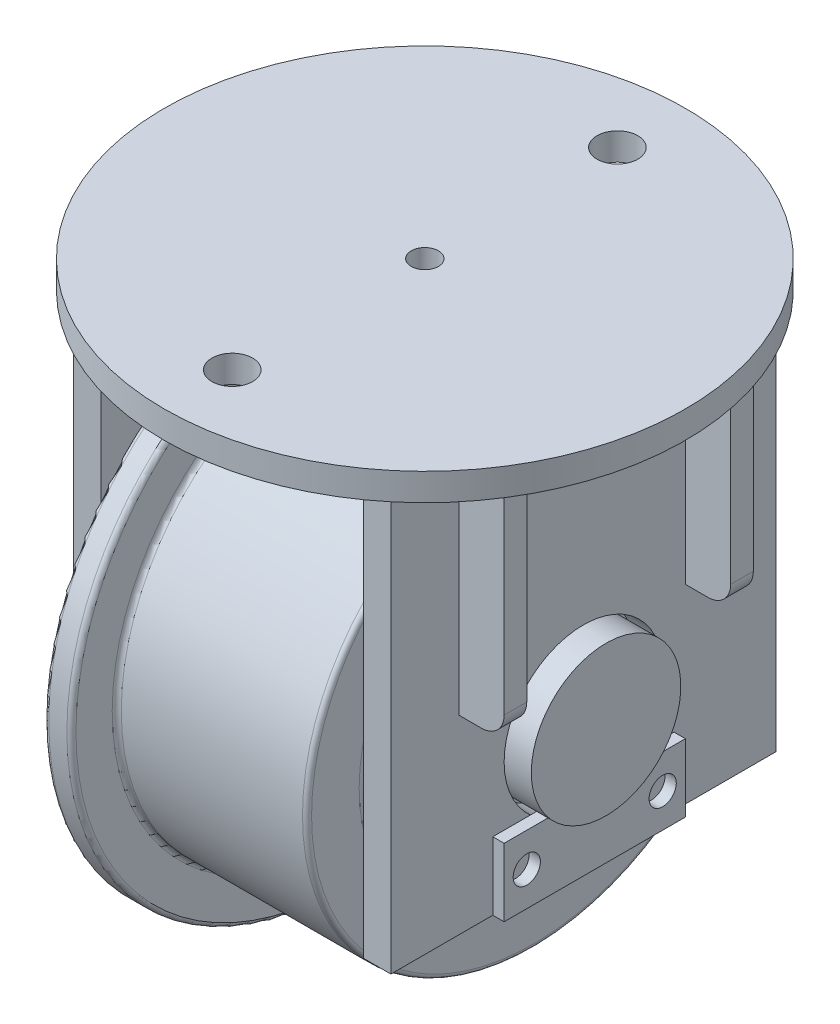
from build123d import *

# Parameters (mm, degrees)
SKETCH1_R            = 115
SKETCH1_R_2          = 9
SKETCH1_R_3          = 6
BOSS_EXTRUDE1_DEPTH  = 6
SKETCH2_W            = 12
SKETCH2_H            = 170
BOSS_EXTRUDE2_DEPTH  = 184
SKETCH3_R            = 35
CUT_EXTRUDE1_DEPTH   = 184
SKETCH6_W            = 10
SKETCH6_H            = 100
EXTRUDE_THIN1_DEPTH  = 20
FILLET2_R            = 10
FILLET2_OF_MIRROR1_R = 10
SKETCH5_W            = 158
SKETCH5_H            = 33
FILLET1_R            = 2
SKETCH7_W            = 80
SKETCH7_H            = 30
SKETCH7_R            = 6
BOSS_EXTRUDE3_DEPTH  = 5


with BuildPart() as part:
    # Sketch1 → Boss-Extrude1 (new body, symmetric)
    with BuildSketch(Plane(origin=(0, 0, 0), x_dir=(1, 0, 0), z_dir=(0, 1, 0))):
        Circle(SKETCH1_R)
        with Locations((0, 85)):
            Circle(SKETCH1_R_2, mode=Mode.SUBTRACT)
        with Locations((0, -85)):
            Circle(SKETCH1_R_2, mode=Mode.SUBTRACT)
        Circle(SKETCH1_R_3, mode=Mode.SUBTRACT)
    extrude(amount=BOSS_EXTRUDE1_DEPTH, both=True)

    # Sketch2 → Boss-Extrude2 (add)
    with BuildSketch(Plane(origin=(0, -6, 0), x_dir=(-1, 0, 0), z_dir=(0, -1, 0))):
        with Locations((64, 0)):
            Rectangle(SKETCH2_W, SKETCH2_H)
    boss_extrude2 = extrude(amount=BOSS_EXTRUDE2_DEPTH)

    # Sketch3 → Cut-Extrude1 (cut)
    with BuildSketch(Plane.ZY.offset(70)):
        with Locations((0, -134)):
            Circle(SKETCH3_R)
    cut_extrude1 = extrude(amount=-CUT_EXTRUDE1_DEPTH, mode=Mode.SUBTRACT)

    # Sketch6 → Extrude-Thin1 (add)
    with BuildSketch(Plane.ZY.offset(70)):
        with Locations((-50, -56)):
            Rectangle(SKETCH6_W, SKETCH6_H)
        with Locations((50, -56)):
            Rectangle(SKETCH6_W, SKETCH6_H)
    extrude_thin1 = extrude(amount=EXTRUDE_THIN1_DEPTH)

    # Fillet2
    fillet2_edges = [part.edges().sort_by_distance(p)[0] for p in [
        (-90, -106, -50),
        (-90, -106, 50),
    ]]
    fillet(fillet2_edges, radius=FILLET2_R)

    # Mirror1: Boss-Extrude2, Cut-Extrude1, Extrude-Thin1 across plane
    add(boss_extrude2.mirror(Plane(origin=(0, 0, 0), x_dir=(0, 0, 1), z_dir=(1, 0, 0))))
    add(cut_extrude1.mirror(Plane(origin=(0, 0, 0), x_dir=(0, 0, 1), z_dir=(1, 0, 0))), mode=Mode.SUBTRACT)
    add(extrude_thin1.mirror(Plane(origin=(0, 0, 0), x_dir=(0, 0, 1), z_dir=(1, 0, 0))))

    # Fillet2 of Mirror1
    fillet2_of_mirror1_edges = [part.edges().sort_by_distance(p)[0] for p in [
        (90, -106, -50),
        (90, -106, 50),
    ]]
    fillet(fillet2_of_mirror1_edges, radius=FILLET2_OF_MIRROR1_R)


with BuildPart() as body_2:
    # Sketch5 → Revolve1 (revolve)
    with BuildSketch(Plane.XY):
        Polygon((-53, -99), (-53, -59), (-48, -59), (-48, -14), (-36, -14), (-36, -34), (48, -34), (48, -59), (53, -59), (53, -99), align=None)
        with Locations((1, -117.5)):
            Rectangle(SKETCH5_W, SKETCH5_H)
    revolve(axis=Axis((-70, -134, 0), (1, 0, 0)))

    # Fillet1
    fillet1_edges = [body_2.edges().sort_by_distance(p)[0] for p in [
        (-36, -254, 0),
        (-48, -254, 0),
        (-48, -209, 0),
        (-53, -209, 0),
        (53, -209, 0),
        (48, -209, 0),
        (48, -234, 0),
        (-36, -234, 0),
    ]]
    fillet(fillet1_edges, radius=FILLET1_R)


with BuildPart() as body_3:
    # Sketch7 → Boss-Extrude3 (new body)
    with BuildSketch(Plane(origin=(70, 0, 0), x_dir=(0, 0, -1), z_dir=(1, 0, 0))):
        with Locations((0, -175)):
            Rectangle(SKETCH7_W, SKETCH7_H)
        with Locations((-30, -175)):
            Circle(SKETCH7_R, mode=Mode.SUBTRACT)
        with Locations((30, -175)):
            Circle(SKETCH7_R, mode=Mode.SUBTRACT)
    extrude(amount=BOSS_EXTRUDE3_DEPTH)


solid = Compound([part.part, body_2.part, body_3.part])
